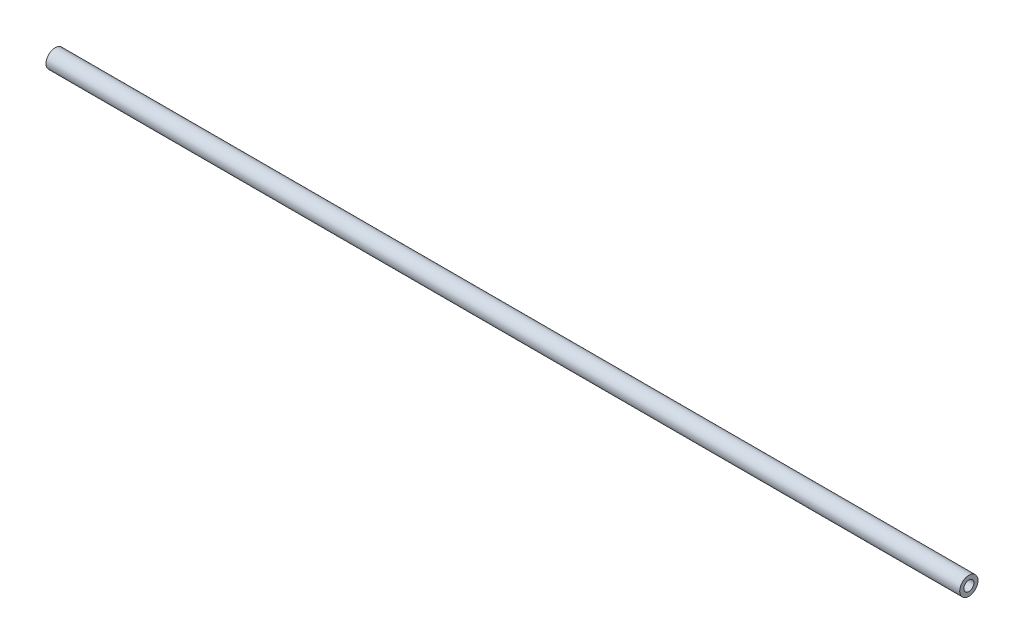
from build123d import *

# Parameters (mm, degrees)
SKETCH1_R                       = 3
BOSS_EXTRUDE1_DEPTH             = 300
M4_TAPPED_HOLE2_D               = 3.3
M4_TAPPED_HOLE2_DEPTH           = 10.1
M4_TAPPED_HOLE2_TIP             = 0.991420021
M4_TAPPED_HOLE2_ON_FACE_2_D     = 3.3
M4_TAPPED_HOLE2_ON_FACE_2_DEPTH = 10.1
M4_TAPPED_HOLE2_ON_FACE_2_TIP   = 0.991420021


with BuildPart() as part:
    # Sketch1 → Boss-Extrude1 (new body)
    with BuildSketch(Plane(origin=(0, 0, 0), x_dir=(0, 0, -1), z_dir=(1, 0, 0))):
        Circle(SKETCH1_R)
    extrude(amount=BOSS_EXTRUDE1_DEPTH)

    # M4 Tapped Hole2
    with Locations(Plane(origin=(0, 0, 0), x_dir=(0, 0, -1), z_dir=(-1, 0, 0))):
        with Locations((0, 0)):
            Hole(M4_TAPPED_HOLE2_D / 2, depth=M4_TAPPED_HOLE2_DEPTH)
            with Locations((0, 0, -(M4_TAPPED_HOLE2_DEPTH + M4_TAPPED_HOLE2_TIP / 2))):  # 118° drill point
                Cone(0, M4_TAPPED_HOLE2_D / 2, M4_TAPPED_HOLE2_TIP, mode=Mode.SUBTRACT)

    # M4 Tapped Hole2 on face 2
    with Locations(Plane(origin=(300, 0, 0), x_dir=(0, 0, 1), z_dir=(1, 0, 0))):
        with Locations((0, 0)):
            Hole(M4_TAPPED_HOLE2_ON_FACE_2_D / 2, depth=M4_TAPPED_HOLE2_ON_FACE_2_DEPTH)
            with Locations((0, 0, -(M4_TAPPED_HOLE2_ON_FACE_2_DEPTH + M4_TAPPED_HOLE2_ON_FACE_2_TIP / 2))):  # 118° drill point
                Cone(0, M4_TAPPED_HOLE2_ON_FACE_2_D / 2, M4_TAPPED_HOLE2_ON_FACE_2_TIP, mode=Mode.SUBTRACT)


solid = part.part
